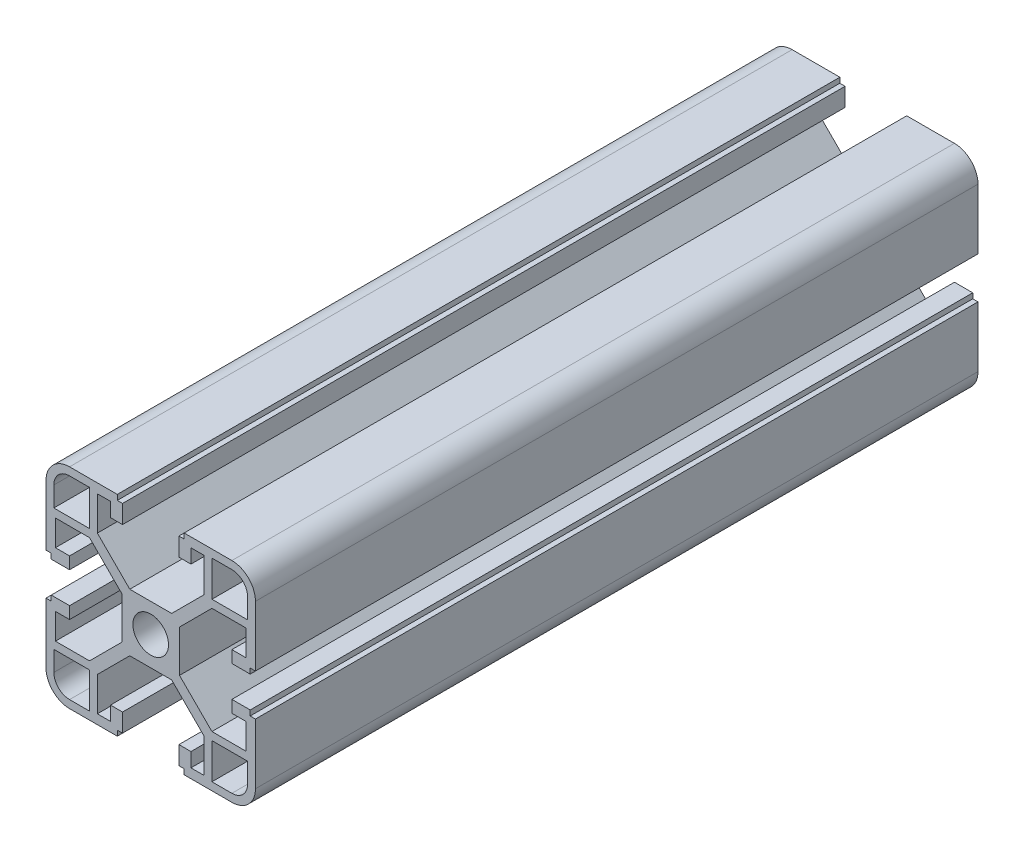
from build123d import *

# Parameters (mm, degrees)
BOSS_EXTRUDE1_DEPTH  = 138
MIRROR3_COPY_1_DEPTH = 138
MIRROR3_COPY_2_DEPTH = 138


with BuildPart() as part:
    # Sketch1 → Boss-Extrude1 (new body)
    with BuildSketch(Plane.XY):
        with BuildLine():
            Line((3.4, 0), (5.5, 0))
            Line((5.5, 0), (5.5, 4))
            Line((5.5, 4), (11.69, 10.19))
            Line((11.69, 10.19), (18.2, 10.19))
            Line((18.2, 10.19), (18.2, 5.265595036))
            Line((18.2, 5.265595036), (15.5, 5.265595036))
            Line((15.5, 5.265595036), (15.5, 2.965595036))
            Line((15.5, 2.965595036), (19, 2.965595036))
            Line((19, 2.965595036), (19, 3.965595036))
            Line((19, 3.965595036), (20, 3.965595036))
            Line((20, 3.965595036), (20, 15.5))
            ThreePointArc((20, 15.5), (18.681980515, 18.681980515), (15.5, 20))
            Line((15.5, 20), (6.385304712, 20))
            Line((6.385304712, 20), (6.385304712, 19))
            Line((6.385304712, 19), (5.385304712, 19))
            Line((5.385304712, 19), (5.385304712, 15.5))
            Line((5.385304712, 15.5), (7.685304712, 15.5))
            Line((7.685304712, 15.5), (7.685304712, 18.2))
            Line((7.685304712, 18.2), (10.19, 18.2))
            Line((10.19, 18.2), (10.19, 11.69))
            Line((10.19, 11.69), (4, 5.5))
            Line((4, 5.5), (0, 5.5))
            Line((0, 5.5), (0, 3.4))
            ThreePointArc((0, 3.4), (2.404163056, 2.404163056), (3.4, 0))
        make_face()
        with BuildLine():
            Line((18.5, 11.69), (18.5, 15.5))
            ThreePointArc((18.5, 15.5), (17.621320344, 17.621320344), (15.5, 18.5))
            Line((15.5, 18.5), (11.69, 18.5))
            Line((11.69, 18.5), (11.69, 11.69))
            Line((11.69, 11.69), (18.5, 11.69))
        make_face(mode=Mode.SUBTRACT)
    boss_extrude1 = extrude(amount=BOSS_EXTRUDE1_DEPTH)

    # Mirror1: Boss-Extrude1 across plane
    add(boss_extrude1.mirror(Plane.ZX))

    # Mirror2: Boss-Extrude1 across plane
    add(boss_extrude1.mirror(Plane(origin=(0, 0, 0), x_dir=(0, 0, 1), z_dir=(1, 0, 0))))

    # Mirror3 copy 1 sketch → Mirror3 copy 1 (add)
    with BuildSketch(Plane(origin=(0, 0, 0), x_dir=(-1, 0, 0), z_dir=(0, 0, 1))):
        with BuildLine():
            Line((3.4, 0), (5.5, 0))
            Line((5.5, 0), (5.5, 4))
            Line((5.5, 4), (11.69, 10.19))
            Line((11.69, 10.19), (18.2, 10.19))
            Line((18.2, 10.19), (18.2, 5.265595036))
            Line((18.2, 5.265595036), (15.5, 5.265595036))
            Line((15.5, 5.265595036), (15.5, 2.965595036))
            Line((15.5, 2.965595036), (19, 2.965595036))
            Line((19, 2.965595036), (19, 3.965595036))
            Line((19, 3.965595036), (20, 3.965595036))
            Line((20, 3.965595036), (20, 15.5))
            ThreePointArc((20, 15.5), (18.681980515, 18.681980515), (15.5, 20))
            Line((15.5, 20), (6.385304712, 20))
            Line((6.385304712, 20), (6.385304712, 19))
            Line((6.385304712, 19), (5.385304712, 19))
            Line((5.385304712, 19), (5.385304712, 15.5))
            Line((5.385304712, 15.5), (7.685304712, 15.5))
            Line((7.685304712, 15.5), (7.685304712, 18.2))
            Line((7.685304712, 18.2), (10.19, 18.2))
            Line((10.19, 18.2), (10.19, 11.69))
            Line((10.19, 11.69), (4, 5.5))
            Line((4, 5.5), (0, 5.5))
            Line((0, 5.5), (0, 3.4))
            ThreePointArc((0, 3.4), (2.404163056, 2.404163056), (3.4, 0))
        make_face()
        with BuildLine():
            Line((18.5, 11.69), (18.5, 15.5))
            ThreePointArc((18.5, 15.5), (17.621320344, 17.621320344), (15.5, 18.5))
            Line((15.5, 18.5), (11.69, 18.5))
            Line((11.69, 18.5), (11.69, 11.69))
            Line((11.69, 11.69), (18.5, 11.69))
        make_face(mode=Mode.SUBTRACT)
    extrude(amount=MIRROR3_COPY_1_DEPTH)

    # Mirror3 copy 2 sketch → Mirror3 copy 2 (add)
    with BuildSketch(Plane.XY):
        with BuildLine():
            Line((3.4, 0), (5.5, 0))
            Line((5.5, 0), (5.5, -4))
            Line((5.5, -4), (11.69, -10.19))
            Line((11.69, -10.19), (18.2, -10.19))
            Line((18.2, -10.19), (18.2, -5.265595036))
            Line((18.2, -5.265595036), (15.5, -5.265595036))
            Line((15.5, -5.265595036), (15.5, -2.965595036))
            Line((15.5, -2.965595036), (19, -2.965595036))
            Line((19, -2.965595036), (19, -3.965595036))
            Line((19, -3.965595036), (20, -3.965595036))
            Line((20, -3.965595036), (20, -15.5))
            ThreePointArc((20, -15.5), (18.681980515, -18.681980515), (15.5, -20))
            Line((15.5, -20), (6.385304712, -20))
            Line((6.385304712, -20), (6.385304712, -19))
            Line((6.385304712, -19), (5.385304712, -19))
            Line((5.385304712, -19), (5.385304712, -15.5))
            Line((5.385304712, -15.5), (7.685304712, -15.5))
            Line((7.685304712, -15.5), (7.685304712, -18.2))
            Line((7.685304712, -18.2), (10.19, -18.2))
            Line((10.19, -18.2), (10.19, -11.69))
            Line((10.19, -11.69), (4, -5.5))
            Line((4, -5.5), (0, -5.5))
            Line((0, -5.5), (0, -3.4))
            ThreePointArc((0, -3.4), (2.404163056, -2.404163056), (3.4, 0))
        make_face()
        with BuildLine():
            Line((18.5, -11.69), (18.5, -15.5))
            ThreePointArc((18.5, -15.5), (17.621320344, -17.621320344), (15.5, -18.5))
            Line((15.5, -18.5), (11.69, -18.5))
            Line((11.69, -18.5), (11.69, -11.69))
            Line((11.69, -11.69), (18.5, -11.69))
        make_face(mode=Mode.SUBTRACT)
    extrude(amount=MIRROR3_COPY_2_DEPTH)


solid = part.part
